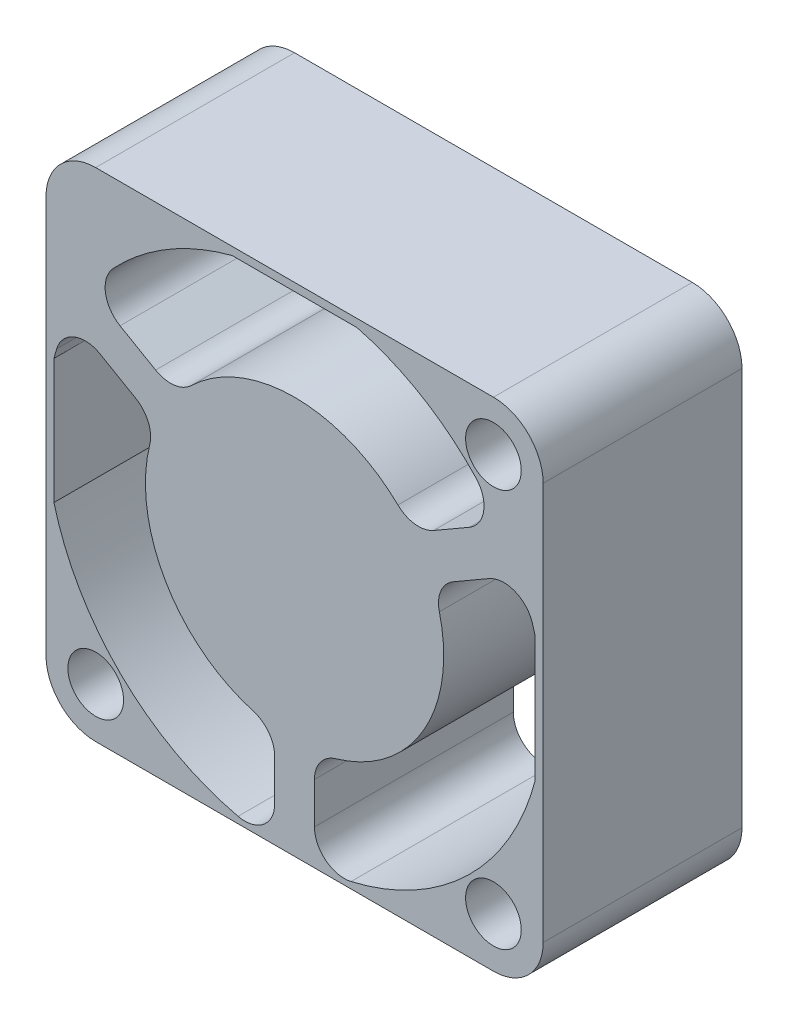
from build123d import *

# Parameters (mm, degrees)
SKETCH1_W                      = 25
SKETCH1_H                      = 25
EXTRUDE1_DEPTH                 = 10
FILLET1_R                      = 2.5
EXTRUDE2_REACH                 = 12
FILLET2_R                      = 1.5
F_2_8_2_8_DIAMETER_HOLE1_D     = 2.8
F_2_8_2_8_DIAMETER_HOLE1_DEPTH = 10


with BuildPart() as part:
    # Sketch1 → Extrude1 (new body)
    with BuildSketch(Plane.XY):
        Rectangle(SKETCH1_W, SKETCH1_H)
    extrude(amount=EXTRUDE1_DEPTH)

    # Fillet1
    fillet1_edges = [part.edges().sort_by_distance(p)[0] for p in [
        (12.5, -12.5, 5),
        (-12.5, -12.5, 5),
        (-12.5, 12.5, 5),
        (12.5, 12.5, 5),
    ]]
    fillet(fillet1_edges, radius=FILLET1_R)

    # Sketch2 → Extrude2 (cut, up to next)
    with BuildSketch(Plane.XY.offset(10), mode=Mode.PRIVATE) as extrude2_sk1:
        with BuildLine():
            Line((-3.136877428, 12.1), (3.136877428, 12.1))
            ThreePointArc((3.136877428, 12.1), (7.164806263, 10.242829258), (10.290620927, 7.095993301))
            Line((10.290620927, 7.095993301), (5.937196595, 4.582542591))
            ThreePointArc((5.937196595, 4.582542591), (0, 7.5), (-5.937196595, 4.582542591))
            Line((-5.937196595, 4.582542591), (-10.290620927, 7.095993301))
            ThreePointArc((-10.290620927, 7.095993301), (-7.164806263, 10.242829258), (-3.136877428, 12.1))
        make_face()
    extrude2_tool1 = extrude(extrude2_sk1.sketch, amount=-EXTRUDE2_REACH, mode=Mode.PRIVATE) & part.part
    add(extrude2_tool1.solids().sort_by_distance((0, 8.698322, 10))[0], mode=Mode.SUBTRACT)
    # Sketch2 → Extrude2 (cut, up to next)
    with BuildSketch(Plane.XY.offset(10), mode=Mode.PRIVATE) as extrude2_sk2:
        with BuildLine():
            Line((12.1, 3.136877428), (12.1, -3.136877428))
            ThreePointArc((12.1, -3.136877428), (8.039425, -9.571710697), (1, -12.459935794))
            Line((1, -12.459935794), (1, -7.433034374))
            ThreePointArc((1, -7.433034374), (6.495190528, -3.75), (6.937196595, 2.850491783))
            Line((6.937196595, 2.850491783), (11.290620927, 5.363942493))
            ThreePointArc((11.290620927, 5.363942493), (11.74820163, 4.269632122), (12.1, 3.136877428))
        make_face()
    extrude2_tool2 = extrude(extrude2_sk2.sketch, amount=-EXTRUDE2_REACH, mode=Mode.PRIVATE) & part.part
    add(extrude2_tool2.solids().sort_by_distance((7.503331, -4.459767, 10))[0], mode=Mode.SUBTRACT)
    # Sketch2 → Extrude2 (cut, up to next)
    with BuildSketch(Plane.XY.offset(10), mode=Mode.PRIVATE) as extrude2_sk3:
        with BuildLine():
            Line((-12.1, 3.136877428), (-12.1, -3.136877428))
            ThreePointArc((-12.1, -3.136877428), (-8.039425, -9.571710697), (-1, -12.459935794))
            Line((-1, -12.459935794), (-1, -7.433034374))
            ThreePointArc((-1, -7.433034374), (-6.495190528, -3.75), (-6.937196595, 2.850491783))
            Line((-6.937196595, 2.850491783), (-11.290620927, 5.363942493))
            ThreePointArc((-11.290620927, 5.363942493), (-11.74820163, 4.269632122), (-12.1, 3.136877428))
        make_face()
    extrude2_tool3 = extrude(extrude2_sk3.sketch, amount=-EXTRUDE2_REACH, mode=Mode.PRIVATE) & part.part
    add(extrude2_tool3.solids().sort_by_distance((-7.503331, -4.459767, 10))[0], mode=Mode.SUBTRACT)

    # Fillet2
    fillet2_edges = [part.edges().sort_by_distance(p)[0] for p in [
        (-10.290620927, 7.095993301, 5),
        (10.290620927, 7.095993301, 5),
        (5.937196595, 4.582542591, 5),
        (-5.937196595, 4.582542591, 5),
        (11.290620927, 5.363942493, 5),
        (1, -12.459935794, 5),
        (1, -7.433034374, 5),
        (6.937196595, 2.850491783, 5),
        (-11.290620927, 5.363942493, 5),
        (-6.937196595, 2.850491783, 5),
        (-1, -7.433034374, 5),
        (-1, -12.459935794, 5),
    ]]
    fillet(fillet2_edges, radius=FILLET2_R)

    # Ø2.8 (2.8) Diameter Hole1
    with Locations(Plane.XY.offset(10)):
        with Locations((10, 10), (10, -10), (-10, -10)):
            Hole(F_2_8_2_8_DIAMETER_HOLE1_D / 2, depth=F_2_8_2_8_DIAMETER_HOLE1_DEPTH)


solid = part.part
